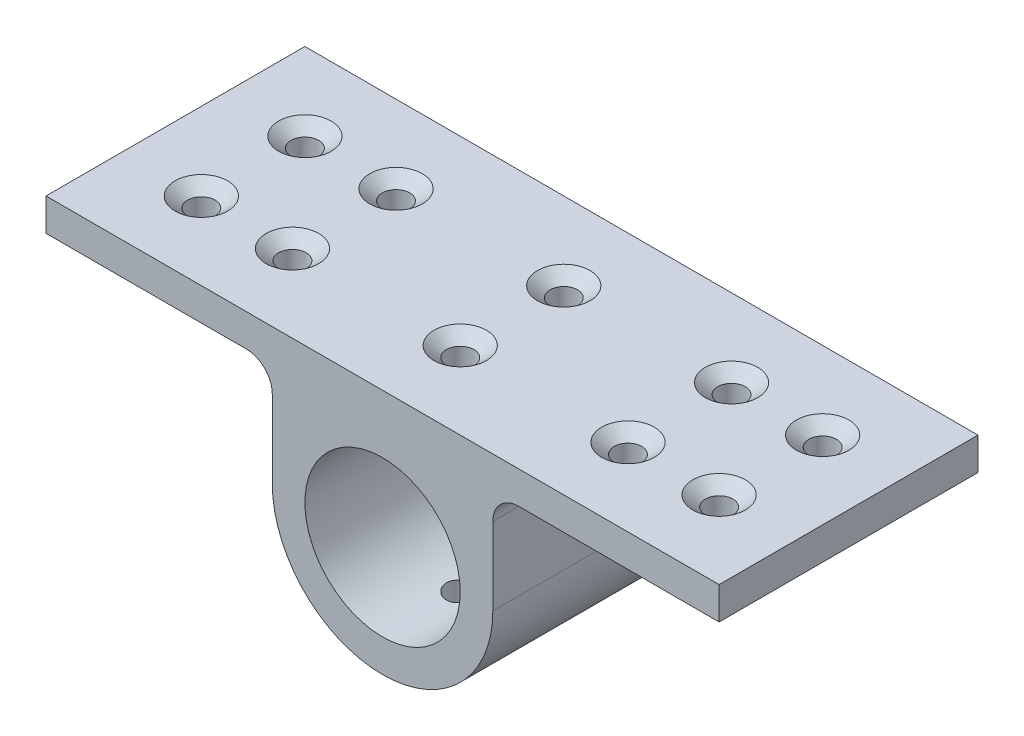
from build123d import *

# Parameters (mm, degrees)
BOSS_EXTRUDE1_DEPTH                                 = 31.75
SKETCH3_R                                           = 19.05
CUT_EXTRUDE1_DEPTH                                  = 64.5
CSK_FOR_1_4_FLAT_HEAD_MACHINE_SCREW_100_D           = 6.7564
CSK_FOR_1_4_FLAT_HEAD_MACHINE_SCREW_100_CSINK_D     = 12.8778
CSK_FOR_1_4_FLAT_HEAD_MACHINE_SCREW_100_CSINK_ANGLE = 100


with BuildPart() as part:
    # Sketch2 → Boss-Extrude1 (new body, symmetric)
    with BuildSketch(Plane.XY):
        with BuildLine():
            Line((82.55, 0), (-82.55, 0))
            Line((-82.55, 0), (-82.55, -7.9502))
            Line((-82.55, -7.9502), (-33.401, -7.9502))
            ThreePointArc((-33.401, -7.9502), (-28.910871939, -9.810071939), (-27.051, -14.3002))
            Line((-27.051, -14.3002), (-27.051, -33.3502))
            ThreePointArc((-27.051, -33.3502), (0, -60.4012), (27.051, -33.3502))
            Line((27.051, -33.3502), (27.051, -14.3002))
            ThreePointArc((27.051, -14.3002), (28.910871939, -9.810071939), (33.401, -7.9502))
            Line((33.401, -7.9502), (82.55, -7.9502))
            Line((82.55, -7.9502), (82.55, 0))
        make_face()
    extrude(amount=BOSS_EXTRUDE1_DEPTH, both=True)

    # Sketch3 → Cut-Extrude1 (cut, through all)
    with BuildSketch(Plane.XY.offset(31.75)):
        with Locations((0, -33.3502)):
            Circle(SKETCH3_R)
    extrude(amount=-CUT_EXTRUDE1_DEPTH, mode=Mode.SUBTRACT)

    # CSK for 1/4 Flat Head Machine Screw (100)2 (through all)
    with Locations(Plane(origin=(0, 0, 0), x_dir=(1, 0, 0), z_dir=(0, 1, 0))):
        with Locations((0, -12.7), (41.148, -12.7), (63.5, -12.7), (-41.148, -12.7), (-63.5, -12.7), (-41.148, 12.7), (-63.5, 12.7), (0, 12.7), (41.148, 12.7), (63.5, 12.7)):
            CounterSinkHole(CSK_FOR_1_4_FLAT_HEAD_MACHINE_SCREW_100_D / 2, CSK_FOR_1_4_FLAT_HEAD_MACHINE_SCREW_100_CSINK_D / 2, counter_sink_angle=CSK_FOR_1_4_FLAT_HEAD_MACHINE_SCREW_100_CSINK_ANGLE)


solid = part.part
